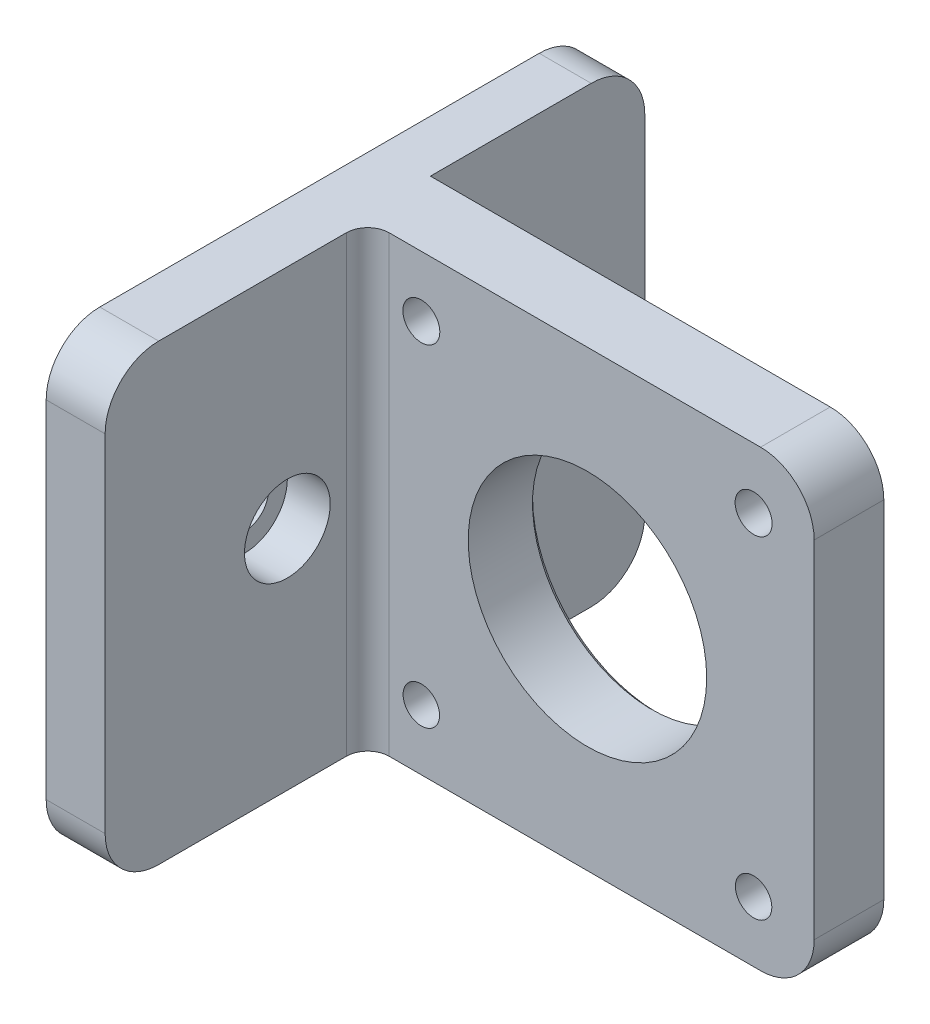
from build123d import *

# Parameters (mm, degrees)
SKETCH1_W                      = 42.3
SKETCH1_H                      = 42.3
BOSS_EXTRUDE1_DEPTH            = 2
M3_CLEARANCE_HOLE1_D           = 3.4
M3_CLEARANCE_HOLE1_CSINK_D     = 3.45
M3_CLEARANCE_HOLE1_CSINK_ANGLE = 90
SKETCH6_R                      = 11.125
CUT_EXTRUDE1_DEPTH             = 5
SKETCH9_W                      = 4.85
SKETCH9_H                      = 42.3
BOSS_EXTRUDE2_DEPTH            = 15
FILLET2_R                      = 5
SKETCH13_W                     = 4.85
SKETCH13_H                     = 42.3
BOSS_EXTRUDE4_DEPTH            = 7
SKETCH14_W                     = 4.85
SKETCH14_H                     = 42.3
BOSS_EXTRUDE5_DEPTH            = 14
CBORE_FOR_M4_SHCS1_D           = 4.5
CBORE_FOR_M4_SHCS1_CBORE_D     = 8
CBORE_FOR_M4_SHCS1_CBORE_DEPTH = 4
FILLET3_R                      = 5
SKETCH19_R                     = 11.125
SKETCH19_R_2                   = 1.725
SKETCH19_R_3                   = 1.7
BOSS_EXTRUDE6_DEPTH            = 2.5
BOSS_EXTRUDE6_DEPTH_BACK       = 4
BOSS_EXTRUDE7_DEPTH            = 0.65
CBORE_FOR_M4_SHCS3_D           = 4.5
CBORE_FOR_M4_SHCS3_CBORE_D     = 8
CBORE_FOR_M4_SHCS3_CBORE_DEPTH = 4
FILLET6_R                      = 2
CHAMFER1_SIZE                  = 0.5


with BuildPart() as part:
    # Sketch1 → Boss-Extrude1 (new body, symmetric)
    with BuildSketch(Plane.XY):
        Rectangle(SKETCH1_W, SKETCH1_H)
    extrude(amount=BOSS_EXTRUDE1_DEPTH, both=True)

    # M3 Clearance Hole1 (through all)
    with Locations(Plane.XY.offset(2)):
        with Locations((-15.5, 15.5), (15.5, 15.5), (15.5, -15.5), (-15.5, -15.5)):
            CounterSinkHole(M3_CLEARANCE_HOLE1_D / 2, M3_CLEARANCE_HOLE1_CSINK_D / 2, counter_sink_angle=M3_CLEARANCE_HOLE1_CSINK_ANGLE)

    # Sketch6 → Cut-Extrude1 (cut, through all)
    with BuildSketch(Plane.XY.offset(2)):
        Circle(SKETCH6_R)
    extrude(amount=-CUT_EXTRUDE1_DEPTH, mode=Mode.SUBTRACT)

    # Sketch9 → Boss-Extrude2 (add, symmetric)
    with BuildSketch(Plane.XY):
        with Locations((-23.575, 0)):
            Rectangle(SKETCH9_W, SKETCH9_H)
    extrude(amount=BOSS_EXTRUDE2_DEPTH, both=True)

    # Fillet2
    fillet2_edges = [part.edges().sort_by_distance(p)[0] for p in [
        (21.15, -21.15, 0),
        (21.15, 21.15, 0),
    ]]
    fillet(fillet2_edges, radius=FILLET2_R)

    # Sketch13 → Boss-Extrude4 (add)
    with BuildSketch(Plane(origin=(0, 0, -15), x_dir=(-1, 0, 0), z_dir=(0, 0, -1))):
        with Locations((23.575, 0)):
            Rectangle(SKETCH13_W, SKETCH13_H)
    extrude(amount=BOSS_EXTRUDE4_DEPTH)

    # Sketch14 → Boss-Extrude5 (add)
    with BuildSketch(Plane.XY.offset(15)):
        with Locations((-23.575, 0)):
            Rectangle(SKETCH14_W, SKETCH14_H)
    extrude(amount=BOSS_EXTRUDE5_DEPTH)

    # CBORE for M4 SHCS1 (through all)
    with Locations(Plane(origin=(-21.15, 0, 0), x_dir=(0, 0, -1), z_dir=(1, 0, 0))):
        with Locations((12, 0)):
            CounterBoreHole(CBORE_FOR_M4_SHCS1_D / 2, CBORE_FOR_M4_SHCS1_CBORE_D / 2, CBORE_FOR_M4_SHCS1_CBORE_DEPTH)

    # Fillet3
    fillet3_edges = [part.edges().sort_by_distance(p)[0] for p in [
        (-23.575, 21.15, -22),
        (-23.575, -21.15, -22),
        (-23.575, -21.15, 29),
        (-23.575, 21.15, 29),
    ]]
    fillet(fillet3_edges, radius=FILLET3_R)

    # Sketch19 → Boss-Extrude6 (add, two sides)
    with BuildSketch(Plane.XY.offset(2)) as boss_extrude6_sk:
        with BuildLine():
            Line((-21.15, -21.15), (16.15, -21.15))
            ThreePointArc((16.15, -21.15), (19.685533906, -19.685533906), (21.15, -16.15))
            Line((21.15, -16.15), (21.15, 16.15))
            ThreePointArc((21.15, 16.15), (19.685533906, 19.685533906), (16.15, 21.15))
            Line((16.15, 21.15), (-21.15, 21.15))
            Line((-21.15, 21.15), (-21.15, -21.15))
        make_face()
        Circle(SKETCH19_R, mode=Mode.SUBTRACT)
        with Locations((15.5, 15.5)):
            Circle(SKETCH19_R_2, mode=Mode.SUBTRACT)
        with Locations((-15.5, 15.5)):
            Circle(SKETCH19_R_2, mode=Mode.SUBTRACT)
        with Locations((-15.5, -15.5)):
            Circle(SKETCH19_R_3, mode=Mode.SUBTRACT)
        with Locations((15.5, -15.5)):
            Circle(SKETCH19_R_3, mode=Mode.SUBTRACT)
    extrude(amount=BOSS_EXTRUDE6_DEPTH)
    extrude(boss_extrude6_sk.sketch, amount=-BOSS_EXTRUDE6_DEPTH_BACK)

    # Sketch21 → Boss-Extrude7 (add)
    with BuildSketch(Plane(origin=(-21.15, 0, 0), x_dir=(0, 0, -1), z_dir=(1, 0, 0))):
        with BuildLine():
            Line((-24, -21.15), (-4.5, -21.15))
            Line((-4.5, -21.15), (-4.5, 21.15))
            Line((-4.5, 21.15), (-24, 21.15))
            ThreePointArc((-24, 21.15), (-27.535533906, 19.685533906), (-29, 16.15))
            Line((-29, 16.15), (-29, -16.15))
            ThreePointArc((-29, -16.15), (-27.535533906, -19.685533906), (-24, -21.15))
        make_face()
    extrude(amount=BOSS_EXTRUDE7_DEPTH)

    # CBORE for M4 SHCS3 (through all)
    with Locations(Plane(origin=(-20.5, 0, 0), x_dir=(0, 0, -1), z_dir=(1, 0, 0))):
        with Locations((-12, 0)):
            CounterBoreHole(CBORE_FOR_M4_SHCS3_D / 2, CBORE_FOR_M4_SHCS3_CBORE_D / 2, CBORE_FOR_M4_SHCS3_CBORE_DEPTH)

    # Fillet6
    fillet6_edges = [part.edges().sort_by_distance(p)[0] for p in [
        (-20.5, 0, 4.5),
    ]]
    fillet(fillet6_edges, radius=FILLET6_R)

    # Chamfer1
    chamfer1_edges = [part.edges().sort_by_distance(p)[0] for p in [
        (-11.125, 0, -2),
    ]]
    chamfer(chamfer1_edges, length=CHAMFER1_SIZE)


solid = part.part
